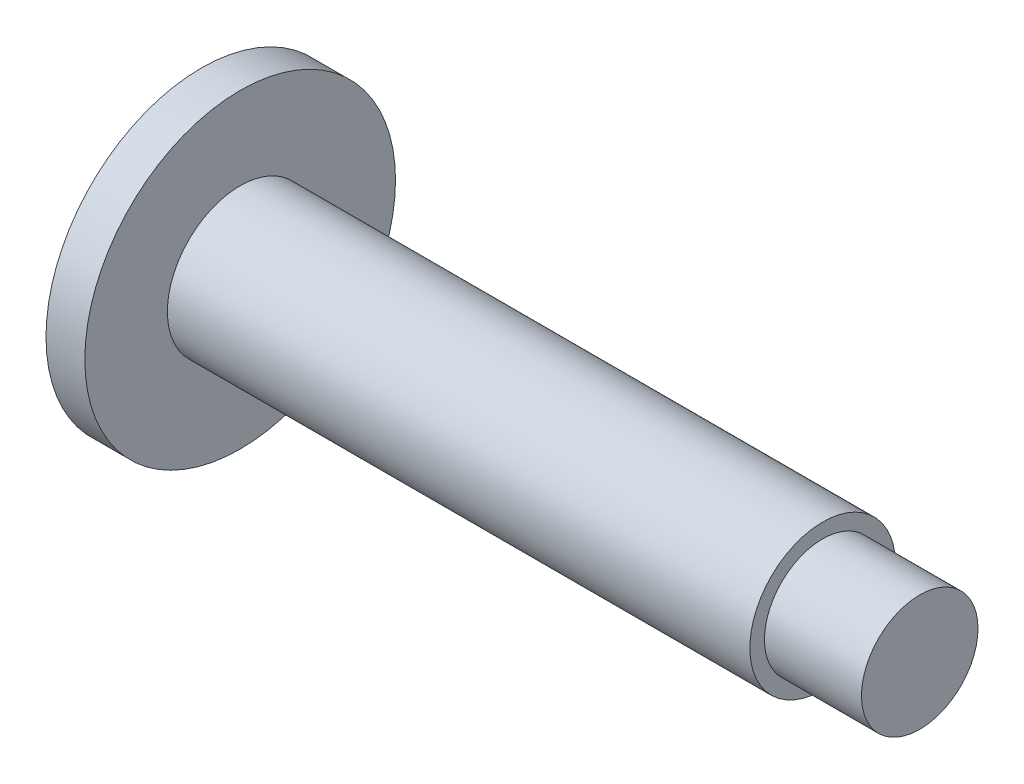
from build123d import *

# Parameters (mm, degrees)
CROQUIS1_R              = 8
SALIENTE_EXTRUIR1_DEPTH = 2
CROQUIS2_R              = 3.75
SALIENTE_EXTRUIR2_DEPTH = 30
CROQUIS3_R              = 3
SALIENTE_EXTRUIR3_DEPTH = 5


with BuildPart() as part:
    # Croquis1 → Saliente-Extruir1 (new body)
    with BuildSketch(Plane(origin=(0, 0, 0), x_dir=(0, 0, -1), z_dir=(1, 0, 0))):
        Circle(CROQUIS1_R)
    extrude(amount=SALIENTE_EXTRUIR1_DEPTH)

    # Croquis2 → Saliente-Extruir2 (add)
    with BuildSketch(Plane(origin=(2, 0, 0), x_dir=(0, 0, -1), z_dir=(1, 0, 0))):
        Circle(CROQUIS2_R)
    extrude(amount=SALIENTE_EXTRUIR2_DEPTH)

    # Croquis3 → Saliente-Extruir3 (add)
    with BuildSketch(Plane(origin=(32, 0, 0), x_dir=(0, 0, -1), z_dir=(1, 0, 0))):
        Circle(CROQUIS3_R)
    extrude(amount=SALIENTE_EXTRUIR3_DEPTH)


solid = part.part
